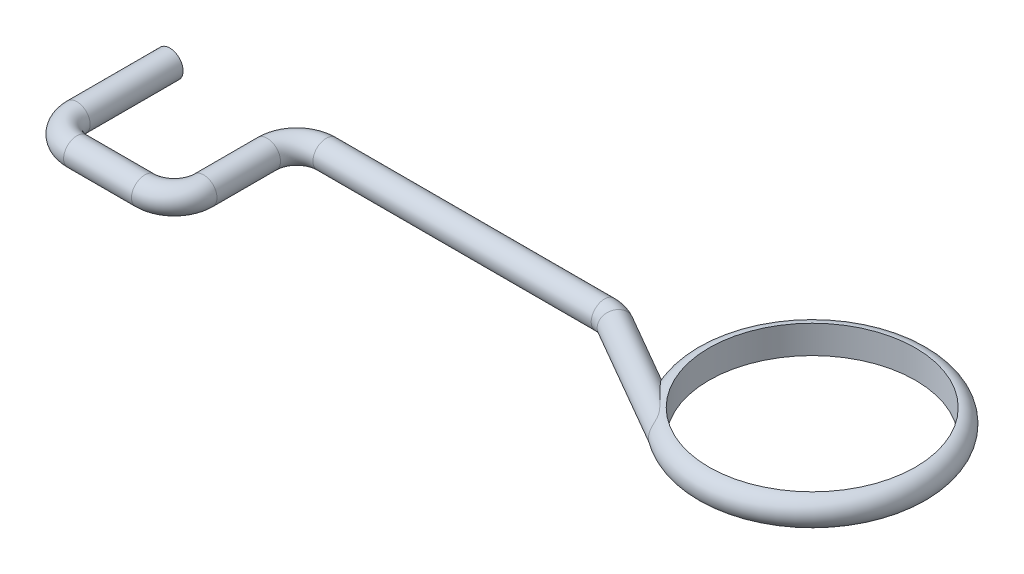
from build123d import *

# Parameters (mm, degrees)
SKETCH2_R               = 0.2286
SKETCH5_R               = 1.778
CUT_EXTRUDE1_DEPTH      = 14.134416106
CUT_EXTRUDE1_DEPTH_BACK = 14.134416106


with BuildPart() as part:
    # Sweep1: sweep along a path in Sketch1
    with BuildLine(Plane(origin=(0, 0, 0), x_dir=(1, 0, 0), z_dir=(0, 1, 0))) as sweep1_path:
        Line((10.006014851, -1.377566316), (7.73788181, -0.068059095))
        ThreePointArc((7.73788181, -0.068059095), (7.615361885, -0.01730968), (7.48388181, 0))
        Line((7.48388181, 0), (2.6924, 0))
        ThreePointArc((2.6924, 0), (2.333189755, -0.148789755), (2.1844, -0.508))
        Line((2.1844, -0.508), (2.1844, -1.6002))
        ThreePointArc((2.1844, -1.6002), (2.035610245, -1.959410245), (1.6764, -2.1082))
        Line((1.6764, -2.1082), (0.508, -2.1082))
        ThreePointArc((0.508, -2.1082), (0.148789755, -1.959410245), (0, -1.6002))
        Line((0, -1.6002), (0, 0))
    # Sketch2 → Sweep1 (sweep)
    with BuildSketch(Plane(origin=(0, 0, 0), x_dir=(-1, 0, 0), z_dir=(0, 0, -1))):
        Circle(SKETCH2_R)
    sweep(path=sweep1_path.line)

    # Sweep2: sweep along a path in Sketch3
    with BuildLine(Plane(origin=(0, 0, 0), x_dir=(1, 0, 0), z_dir=(0, 1, 0))) as sweep2_path:
        CenterArc((10.904145983, 0.156918766), 1.778, 0, 360)
    # Sketch4 → Sweep2 (sweep)
    with BuildSketch(Plane(origin=(0, 0, 0), x_dir=(-1, 0, 0), z_dir=(0, 0, -1))):
        with BuildLine():
            Line((-12.675207953, 0.2413), (-12.675207953, -0.2413))
            ThreePointArc((-12.675207953, -0.2413), (-12.916507953, 0), (-12.675207953, 0.2413))
        make_face()
    sweep(path=sweep2_path.line)

    # Sketch5 → Cut-Extrude1 (cut, two sides)
    with BuildSketch(Plane(origin=(0, 0, 0), x_dir=(1, 0, 0), z_dir=(0, 1, 0))) as cut_extrude1_sk:
        with Locations(Location((10.904145983, 0.156918766, 0), (0, 0, 90))):
            Circle(SKETCH5_R)
    extrude(amount=CUT_EXTRUDE1_DEPTH, mode=Mode.SUBTRACT)
    extrude(cut_extrude1_sk.sketch, amount=-CUT_EXTRUDE1_DEPTH_BACK, mode=Mode.SUBTRACT)


solid = part.part
